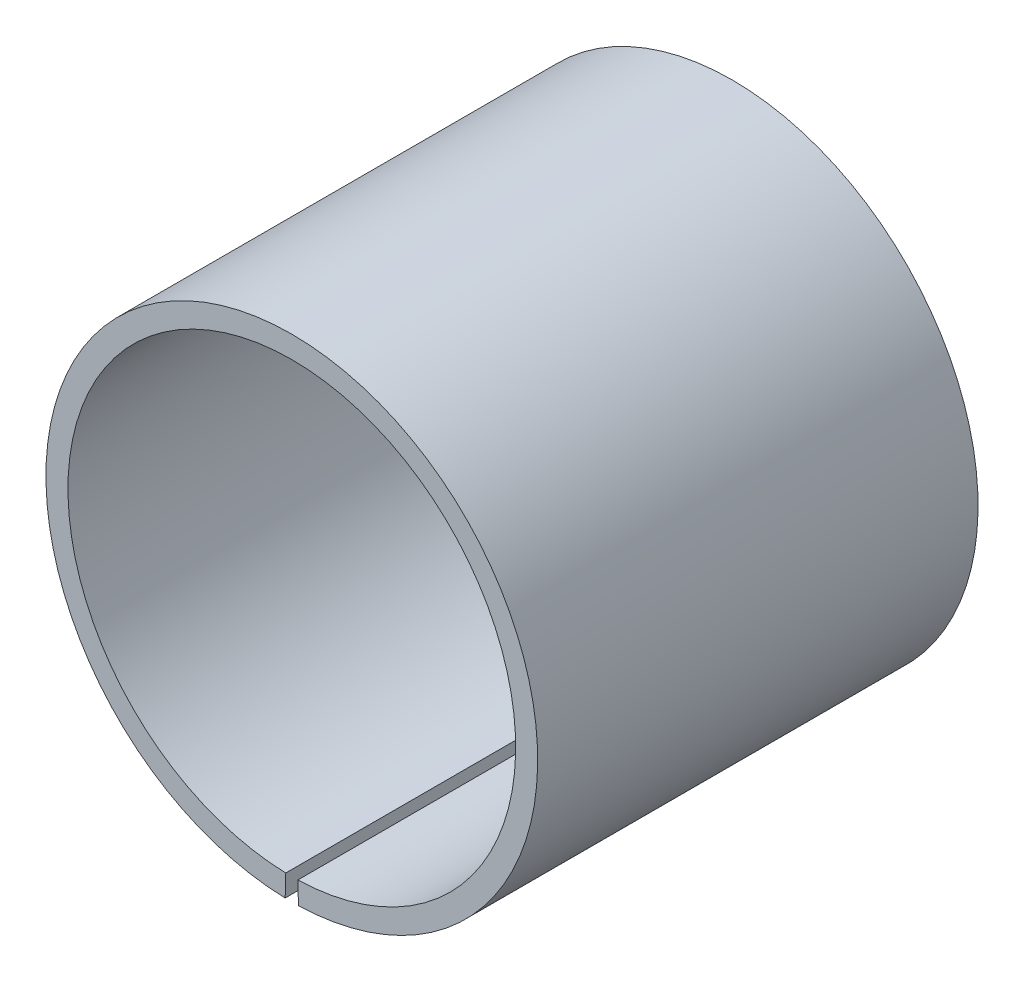
from build123d import *

# Parameters (mm, degrees)
BOSS_EXTRUDE1_DEPTH = 15


with BuildPart() as part:
    # Sketch1 → Boss-Extrude1 (new body, symmetric)
    with BuildSketch(Plane.XY):
        with BuildLine():
            Line((-0.411831327, -15.244438165), (-0.452339326, -16.743891099))
            ThreePointArc((-0.452339326, -16.743891099), (0, 16.75), (0.452339326, -16.743891099))
            Line((0.452339326, -16.743891099), (0.411831327, -15.244438165))
            ThreePointArc((0.411831327, -15.244438165), (0, 15.25), (-0.411831327, -15.244438165))
        make_face()
    extrude(amount=BOSS_EXTRUDE1_DEPTH, both=True)


solid = part.part
